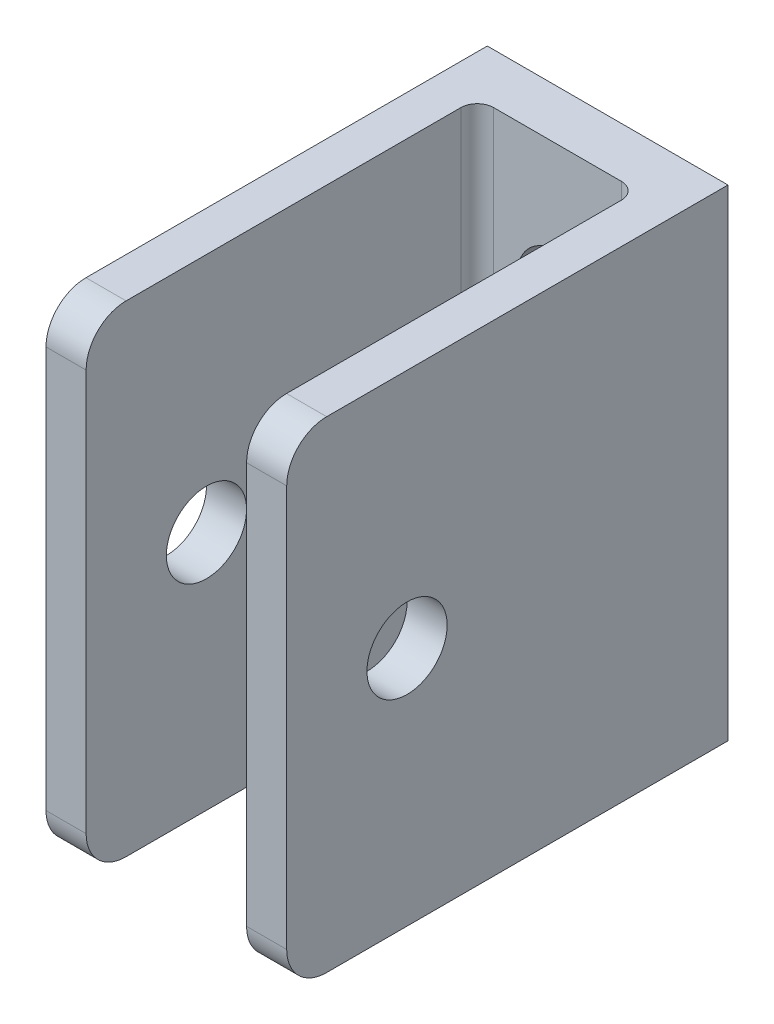
from build123d import *

# Parameters (mm, degrees)
EXTRUDE1_DEPTH      = 19.05
SKETCH2_R           = 3.175
EXTRUDE2_DEPTH      = 35.925
SKETCH3_R           = 3.175
EXTRUDE3_DEPTH      = 10.525
EXTRUDE3_DEPTH_BACK = 10.525
FILLET3_R           = 3.1623
FILLET4_R           = 1.30175


with BuildPart() as part:
    # Sketch1 → Extrude1 (new body, symmetric)
    with BuildSketch(Plane(origin=(0, 0, 0), x_dir=(1, 0, 0), z_dir=(0, 1, 0))):
        Polygon((-9.525, 0), (9.525, 0), (9.525, -34.925), (6.35, -34.925), (6.35, -3.96875), (-6.35, -3.96875), (-6.35, -34.925), (-9.525, -34.925), align=None)
    extrude(amount=EXTRUDE1_DEPTH, both=True)

    # Sketch2 → Extrude2 (cut, through all)
    with BuildSketch(Plane.XY):
        with Locations((0, -8.5725)):
            Circle(SKETCH2_R)
        with Locations((0, 8.5725)):
            Circle(SKETCH2_R)
    extrude(amount=EXTRUDE2_DEPTH, mode=Mode.SUBTRACT)

    # Sketch3 → Extrude3 (cut, two sides)
    with BuildSketch(Plane(origin=(0, 0, -0.669808337), x_dir=(0, 0, -1), z_dir=(1, 0, 0))) as extrude3_sk:
        with Locations((-26.069808337, 0)):
            Circle(SKETCH3_R)
    extrude(amount=EXTRUDE3_DEPTH, mode=Mode.SUBTRACT)
    extrude(extrude3_sk.sketch, amount=-EXTRUDE3_DEPTH_BACK, mode=Mode.SUBTRACT)

    # Fillet3
    fillet3_edges = [part.edges().sort_by_distance(p)[0] for p in [
        (-7.9375, 19.05, 34.925),
        (7.9375, 19.05, 34.925),
        (7.9375, -19.05, 34.925),
        (-7.9375, -19.05, 34.925),
    ]]
    fillet(fillet3_edges, radius=FILLET3_R)

    # Fillet4
    fillet4_edges = [part.edges().sort_by_distance(p)[0] for p in [
        (6.35, 0, 3.96875),
        (-6.35, 0, 3.96875),
    ]]
    fillet(fillet4_edges, radius=FILLET4_R)


solid = part.part
